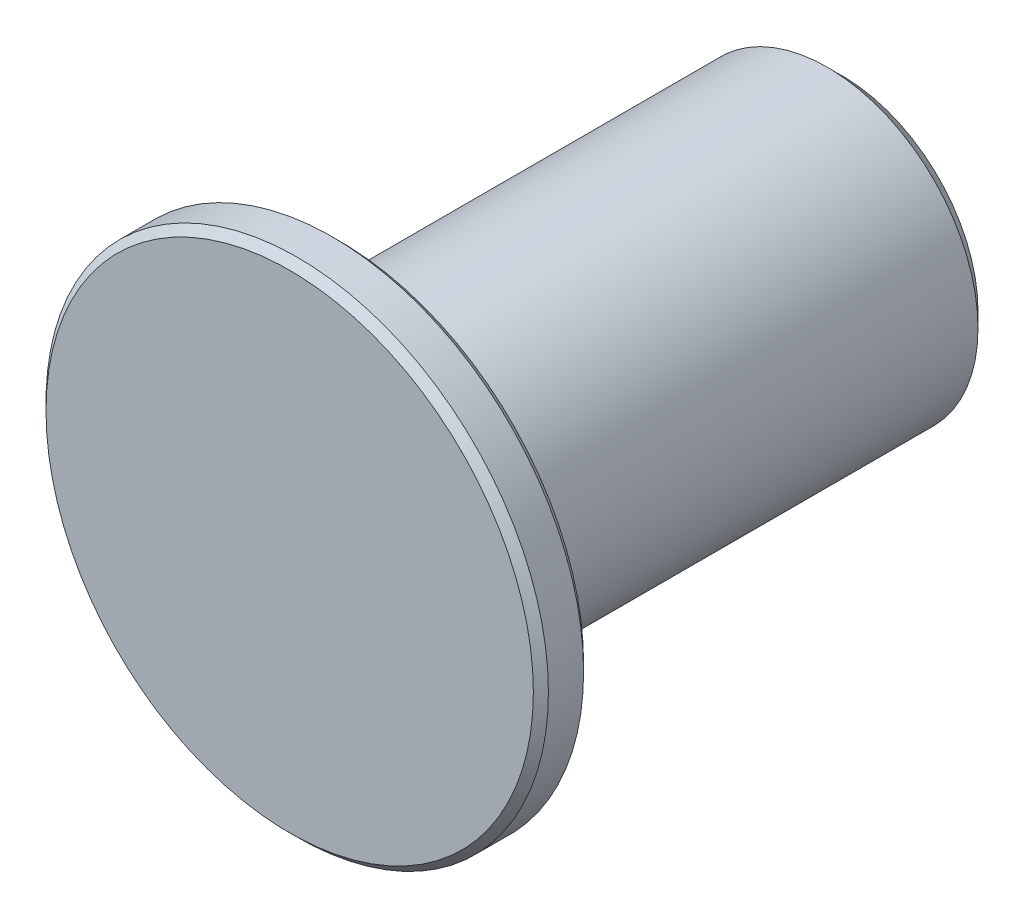
from build123d import *

# Parameters (mm, degrees)
SKETCH2_R           = 6
BOSS_EXTRUDE1_DEPTH = 20
SKETCH3_R           = 10
BOSS_EXTRUDE2_DEPTH = 2
CHAMFER1_SIZE       = 0.6
CHAMFER2_SIZE       = 0.3


with BuildPart() as part:
    # Sketch2 → Boss-Extrude1 (new body)
    with BuildSketch(Plane.XY):
        Circle(SKETCH2_R)
    extrude(amount=BOSS_EXTRUDE1_DEPTH)

    # Sketch3 → Boss-Extrude2 (add)
    with BuildSketch(Plane.XY.offset(20)):
        Circle(SKETCH3_R)
    extrude(amount=BOSS_EXTRUDE2_DEPTH)

    # Chamfer1
    chamfer1_edges = [part.edges().sort_by_distance(p)[0] for p in [
        (-6, 0, 0),
    ]]
    chamfer(chamfer1_edges, length=CHAMFER1_SIZE)

    # Chamfer2
    chamfer2_edges = [part.edges().sort_by_distance(p)[0] for p in [
        (-10, 0, 20),
        (-10, 0, 22),
    ]]
    chamfer(chamfer2_edges, length=CHAMFER2_SIZE)


solid = part.part
